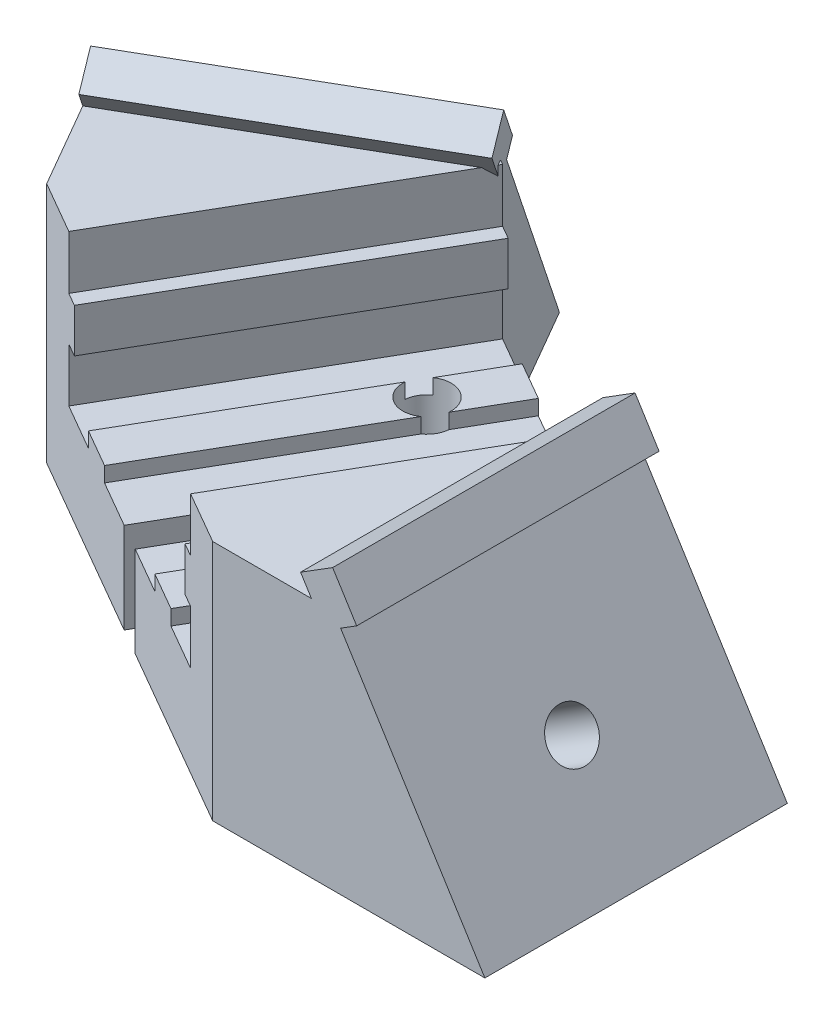
from build123d import *

# Parameters (mm, degrees)
MAIN_DEPTH                     = 20
ESQUISSE2_R                    = 1.6
HOLEFORLAUNCHERFIXING_DEPTH    = 26.158736213
ESQUISSE4_W                    = 22.287049145
ESQUISSE4_H                    = 34.815979295
ENL_V_MAT_EXTRU_3_DEPTH        = 6
MAKERBEANFIXING_DEPTH          = 21
ESQUISSE6_W                    = 20
ESQUISSE6_H                    = 3
ANTIROTATIONSYSTEM_DEPTH       = 1.25
ESQUISSE7_R                    = 1.6
TOPMAKERBEANFIXINGHOLE_DEPTH   = 30.249238927
ENL_V_MAT_EXTRU_4_DEPTH        = 33.636141089
ESQUISSE3_R                    = 4.25
BIGHOLEFORLAUNCHERFIXING_DEPTH = 32.680552778


with BuildPart() as part:
    # Esquisse1 → Main (new body)
    with BuildSketch(Plane.XY):
        Polygon((8, 16), (17.997909631, 0), (0, 0), (0, 16), align=None)
    extrude(amount=MAIN_DEPTH)

    # Esquisse2 → HoleForLauncherFixing (cut, through all)
    with BuildSketch(Plane(origin=(12.943836958, 8.088207011, 0), x_dir=(0, 0, -1), z_dir=(0.8480480961564272, 0.5299192642332031, 0))):
        with Locations((-10, -1.537439029)):
            Circle(ESQUISSE2_R)
    extrude(amount=-HOLEFORLAUNCHERFIXING_DEPTH, mode=Mode.SUBTRACT)

    # Esquisse4 → Enlèv. mat.-Extru.3 (cut)
    with BuildSketch(Plane(origin=(0, 0, 0), x_dir=(0, -1, 0), z_dir=(-0.8660254037844398, 0, -0.499999999999998))):
        with Locations((-6.644134867, 0.407683814)):
            Rectangle(ESQUISSE4_W, ESQUISSE4_H)
    extrude(amount=-ENL_V_MAT_EXTRU_3_DEPTH, mode=Mode.SUBTRACT)

    # Esquisse5 → MakerBeanFixing (add)
    with BuildSketch(Plane(origin=(-3.464101615, 0, 18), x_dir=(-0.8660254037844398, 0, -0.49999999999999806), z_dir=(0.499999999999998, 0, -0.8660254037844397))):
        Polygon((-4, 0), (10, 0), (10, 6), (6.45, 6), (6.45, 7), (3.55, 7), (3.55, 6), (0, 6), (0, 9.55), (1, 9.55), (1, 12.45), (0, 12.45), (0, 16), (-4, 16), align=None)
    extrude(amount=MAKERBEANFIXING_DEPTH)

    # Esquisse6 → AntiRotationSystem (add, symmetric)
    with BuildSketch(Plane(origin=(12.943836958, 8.088207011, 0), x_dir=(0, 0, -1), z_dir=(0.8480480961564272, 0.529919264233203, 0))):
        with Locations((-10, 9.962560971)):
            Rectangle(ESQUISSE6_W, ESQUISSE6_H)
    extrude(amount=ANTIROTATIONSYSTEM_DEPTH, both=True)

    # Esquisse7 → TopMakerBeanFixingHole (cut, through all)
    with BuildSketch(Plane(origin=(0, 7, 0), x_dir=(1, 0, 0), z_dir=(0, 1, 0))):
        with Locations((0.205771366, -1.643593539)):
            Circle(ESQUISSE7_R)
    extrude(amount=-TOPMAKERBEANFIXINGHOLE_DEPTH, mode=Mode.SUBTRACT)

    # Esquisse8 → Enlèv. mat.-Extru.4 (cut, through all)
    with BuildSketch(Plane(origin=(0, 0, 0), x_dir=(-1, 0, 0), z_dir=(0, 0, -1))):
        Polygon((-8.459362874, 15.264865731), (-17.997909631, 0), (-21.602114039, 2.252156873), (-10.47380949, 20.061166892), (-7.929665202, 18.4714091), (-9.519422995, 15.927264811), align=None)
    extrude(amount=-ENL_V_MAT_EXTRU_4_DEPTH, mode=Mode.SUBTRACT)

    # Esquisse3 → BigHoleForLauncherFixing (cut, through all)
    with BuildSketch(Plane(origin=(8.703596477, 5.43861069, 0), x_dir=(0, 0, -1), z_dir=(0.8480480961564272, 0.5299192642332031, 0))):
        with Locations((-10, -1.537439029)):
            Circle(ESQUISSE3_R)
    extrude(amount=-BIGHOLEFORLAUNCHERFIXING_DEPTH, mode=Mode.SUBTRACT)


with BuildPart() as body_2:
    # Mirror1: mirrored copy
    add(part.part.mirror(Plane(origin=(-4.330127019, 0, -2.5), x_dir=(-0.499999999999998, 0, 0.8660254037844398), z_dir=(-0.8660254037844398, 0, -0.499999999999998))))


solid = Compound([part.part, body_2.part])
